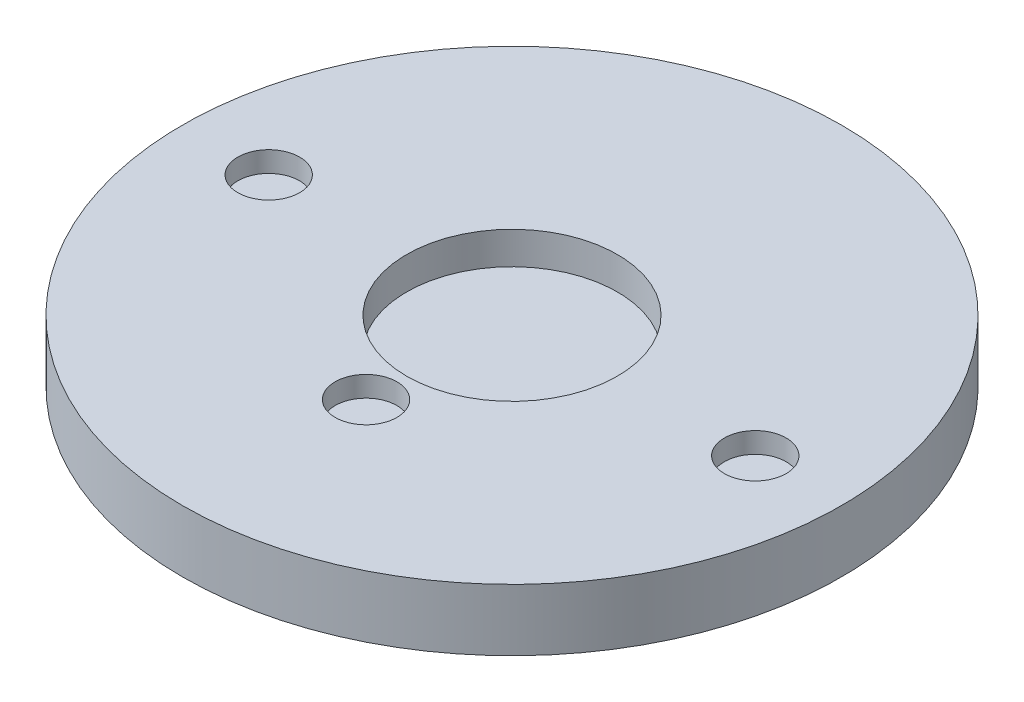
from build123d import *

# Parameters (mm, degrees)
SKETCH1_R           = 101.6
BOSS_EXTRUDE1_DEPTH = 19.05
SKETCH2_R           = 32.5
CUT_EXTRUDE1_DEPTH  = 10
SKETCH4_R           = 9.525
CUT_EXTRUDE3_DEPTH  = 6.35
SKETCH5_R           = 9.525
CUT_EXTRUDE4_DEPTH  = 6.35
SKETCH6_R           = 9.525
CUT_EXTRUDE5_DEPTH  = 6.35


with BuildPart() as part:
    # Sketch1 → Boss-Extrude1 (new body)
    with BuildSketch(Plane(origin=(0, 0, 0), x_dir=(1, 0, 0), z_dir=(0, 1, 0))):
        Circle(SKETCH1_R)
    extrude(amount=BOSS_EXTRUDE1_DEPTH)

    # Sketch2 → Cut-Extrude1 (cut)
    with BuildSketch(Plane(origin=(0, 19.05, 0), x_dir=(1, 0, 0), z_dir=(0, 1, 0))):
        Circle(SKETCH2_R)
    extrude(amount=-CUT_EXTRUDE1_DEPTH, mode=Mode.SUBTRACT)

    # Sketch4 → Cut-Extrude3 (cut)
    with BuildSketch(Plane(origin=(0, 19.05, 0), x_dir=(1, 0, 0), z_dir=(0, 1, 0))):
        with Locations((-75, 0)):
            Circle(SKETCH4_R)
    extrude(amount=-CUT_EXTRUDE3_DEPTH, mode=Mode.SUBTRACT)

    # Sketch5 → Cut-Extrude4 (cut)
    with BuildSketch(Plane(origin=(0, 19.05, 0), x_dir=(1, 0, 0), z_dir=(0, 1, 0))):
        with Locations((75, 0)):
            Circle(SKETCH5_R)
    extrude(amount=-CUT_EXTRUDE4_DEPTH, mode=Mode.SUBTRACT)

    # Sketch6 → Cut-Extrude5 (cut)
    with BuildSketch(Plane(origin=(0, 19.05, 0), x_dir=(1, 0, 0), z_dir=(0, 1, 0))):
        with Locations((0, -45)):
            Circle(SKETCH6_R)
    extrude(amount=-CUT_EXTRUDE5_DEPTH, mode=Mode.SUBTRACT)


solid = part.part
